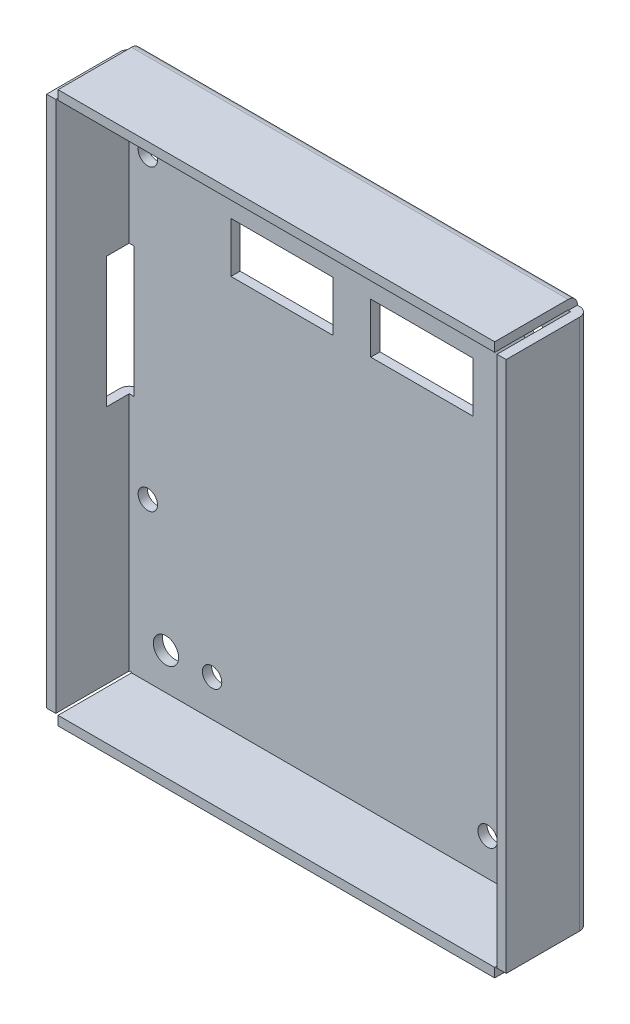
from build123d import *

# Parameters (mm, degrees)
SKETCH1_W           = 100.1
SKETCH1_H           = 120
SKETCH1_R           = 2.75
SKETCH1_R_2         = 2.11
SKETCH1_W_2         = 22.25
SKETCH1_H_2         = 10.95
BOSS_EXTRUDE1_DEPTH = 2
SKETCH2_W           = 2
SKETCH2_H           = 115.8
BOSS_EXTRUDE2_DEPTH = 16
SKETCH4_W           = 95.1
SKETCH4_H           = 2
BOSS_EXTRUDE3_DEPTH = 16
SKETCH5_W           = 2.5
SKETCH5_H           = 2.1
CUT_EXTRUDE1_DEPTH  = 2
SKETCH6_W           = 7
SKETCH6_H           = 28.4
CUT_EXTRUDE2_DEPTH  = 3
FILLET2_R           = 2


with BuildPart() as part:
    # Sketch1 → Boss-Extrude1 (new body)
    with BuildSketch(Plane.XY):
        with Locations((50.05, -60)):
            Rectangle(SKETCH1_W, SKETCH1_H)
        with Locations((10, -10)):
            Circle(SKETCH1_R, mode=Mode.SUBTRACT)
        with Locations((90.1, -10)):
            Circle(SKETCH1_R, mode=Mode.SUBTRACT)
        with Locations((10, -110)):
            Circle(SKETCH1_R, mode=Mode.SUBTRACT)
        with Locations((6.05, -18.5)):
            Circle(SKETCH1_R_2, mode=Mode.SUBTRACT)
        with Locations((6.05, -83.5)):
            Circle(SKETCH1_R_2, mode=Mode.SUBTRACT)
        with Locations((94.05, -18.5)):
            Circle(SKETCH1_R_2, mode=Mode.SUBTRACT)
        with Locations((94.05, -83.5)):
            Circle(SKETCH1_R_2, mode=Mode.SUBTRACT)
        with Locations((20.05, -10)):
            Circle(SKETCH1_R_2, mode=Mode.SUBTRACT)
        with Locations((80.05, -10)):
            Circle(SKETCH1_R_2, mode=Mode.SUBTRACT)
        with Locations((20.05, -110)):
            Circle(SKETCH1_R_2, mode=Mode.SUBTRACT)
        with Locations((80.05, -110)):
            Circle(SKETCH1_R_2, mode=Mode.SUBTRACT)
        with Locations((90.1, -110)):
            Circle(SKETCH1_R, mode=Mode.SUBTRACT)
        with Locations((50.05, -10)):
            Circle(SKETCH1_R, mode=Mode.SUBTRACT)
        with Locations((35.275, -26.925)):
            Rectangle(SKETCH1_W_2, SKETCH1_H_2, mode=Mode.SUBTRACT)
        with Locations((65.725, -26.925)):
            Rectangle(SKETCH1_W_2, SKETCH1_H_2, mode=Mode.SUBTRACT)
    extrude(amount=BOSS_EXTRUDE1_DEPTH)

    # Sketch2 → Boss-Extrude2 (add)
    with BuildSketch(Plane.XY.offset(2)):
        with Locations((1, -60)):
            Rectangle(SKETCH2_W, SKETCH2_H)
    boss_extrude2 = extrude(amount=BOSS_EXTRUDE2_DEPTH)

    # Mirror1: Boss-Extrude2 across plane
    add(boss_extrude2.mirror(Plane(origin=(50.05, 0, 0), x_dir=(0, 0, 1), z_dir=(1, 0, 0))))

    # Sketch4 → Boss-Extrude3 (add)
    with BuildSketch(Plane.XY.offset(2)):
        with Locations((50.05, -1)):
            Rectangle(SKETCH4_W, SKETCH4_H)
        with Locations((50.05, -119)):
            Rectangle(SKETCH4_W, SKETCH4_H)
    extrude(amount=BOSS_EXTRUDE3_DEPTH)

    # Sketch5 → Cut-Extrude1 (cut)
    with BuildSketch(Plane(origin=(0, 0, 0), x_dir=(-1, 0, 0), z_dir=(0, 0, -1))):
        with Locations((-1.25, -1.05)):
            Rectangle(SKETCH5_W, SKETCH5_H)
        with Locations((-98.85, -118.95)):
            Rectangle(SKETCH5_W, SKETCH5_H)
        with Locations((-1.25, -118.95)):
            Rectangle(SKETCH5_W, SKETCH5_H)
        with Locations((-98.85, -1.05)):
            Rectangle(SKETCH5_W, SKETCH5_H)
    extrude(amount=-CUT_EXTRUDE1_DEPTH, mode=Mode.SUBTRACT)

    # Sketch6 → Cut-Extrude2 (cut)
    with BuildSketch(Plane.ZY):
        with Locations((3.5, -51.4)):
            Rectangle(SKETCH6_W, SKETCH6_H)
    extrude(amount=-CUT_EXTRUDE2_DEPTH, mode=Mode.SUBTRACT)

    # Fillet2
    fillet2_edges = [part.edges().sort_by_distance(p)[0] for p in [
        (0, -19.65, 0),
        (100.1, -60, 0),
        (50.05, -120, 0),
        (50.05, 0, 0),
        (0, -91.75, 0),
    ]]
    fillet(fillet2_edges, radius=FILLET2_R)


solid = part.part
